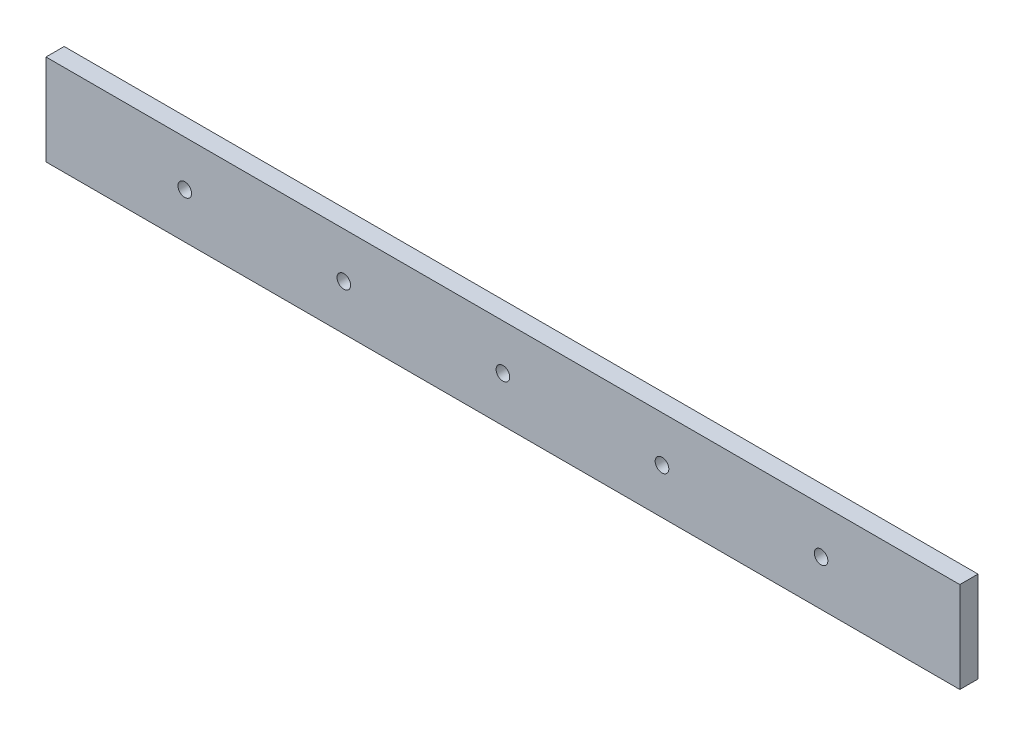
from build123d import *

# Parameters (mm, degrees)
SKETCH1_W               = 201.06
SKETCH1_H               = 4
BOSS_EXTRUDE1_DEPTH     = 20
SKETCH2_R               = 1.5
CUT_EXTRUDE1_DEPTH      = 1
CUT_EXTRUDE1_DEPTH_BACK = 5


with BuildPart() as part:
    # Sketch1 → Boss-Extrude1 (new body)
    with BuildSketch(Plane(origin=(0, 0, 0), x_dir=(1, 0, 0), z_dir=(0, 1, 0))):
        Rectangle(SKETCH1_W, SKETCH1_H)
    extrude(amount=BOSS_EXTRUDE1_DEPTH)

    # Sketch2 → Cut-Extrude1 (cut, two sides)
    with BuildSketch(Plane.XY.offset(2)) as cut_extrude1_sk:
        with Locations((-70, 10)):
            Circle(SKETCH2_R)
        with Locations((-35, 10)):
            Circle(SKETCH2_R)
        with Locations((0, 10)):
            Circle(SKETCH2_R)
        with Locations((35, 10)):
            Circle(SKETCH2_R)
        with Locations((70, 10)):
            Circle(SKETCH2_R)
    extrude(amount=CUT_EXTRUDE1_DEPTH, mode=Mode.SUBTRACT)
    extrude(cut_extrude1_sk.sketch, amount=-CUT_EXTRUDE1_DEPTH_BACK, mode=Mode.SUBTRACT)


solid = part.part
